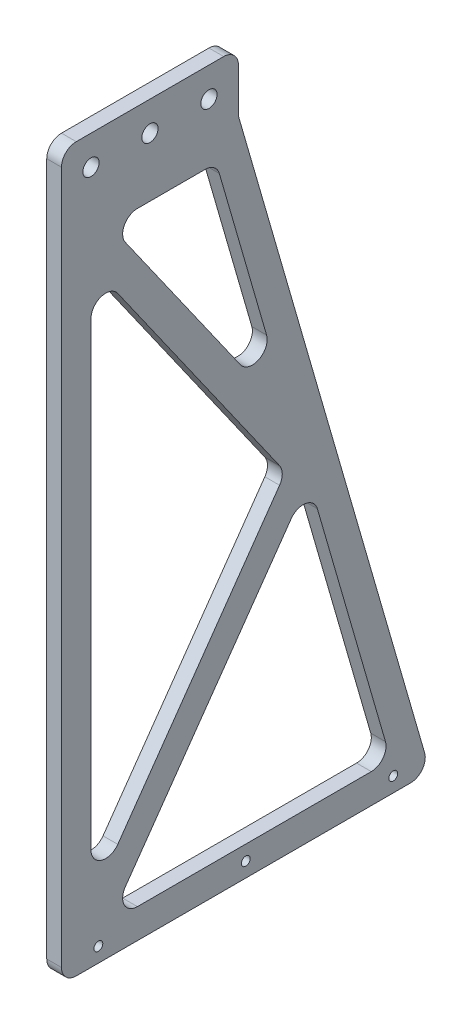
from build123d import *

# Parameters (mm, degrees)
SKETCH1_R            = 1.5
BOSS_EXTRUDE1_DEPTH  = 5
M5_CLEARANCE_HOLE1_D = 5.5
FILLET2_R            = 5


with BuildPart() as part:
    # Sketch1 → Boss-Extrude1 (new body)
    with BuildSketch(Plane(origin=(0, 0, 0), x_dir=(0, 0, -1), z_dir=(1, 0, 0))):
        Polygon((95, -235), (30, -10), (30, 10), (-30, 10), (-30, -235), align=None)
        with Locations((-17.5, -230)):
            Circle(SKETCH1_R, mode=Mode.SUBTRACT)
        with Locations((32.5, -230)):
            Circle(SKETCH1_R, mode=Mode.SUBTRACT)
        with Locations((82.5, -230)):
            Circle(SKETCH1_R, mode=Mode.SUBTRACT)
        Polygon((-13.887165787, -225), (53.870859832, -128.66078689), (81.702188063, -225), align=None, mode=Mode.SUBTRACT)
        Polygon((-20, -216.308695426), (-20, -28.691304574), (45.978242739, -122.5), align=None, mode=Mode.SUBTRACT)
        Polygon((22.479965841, -20), (47.830060977, -107.750329315), (-13.887165787, -20), align=None, mode=Mode.SUBTRACT)
    extrude(amount=BOSS_EXTRUDE1_DEPTH)

    # M5 Clearance Hole1 (through all)
    with Locations(Plane(origin=(5, 0, 0), x_dir=(0, 0, -1), z_dir=(1, 0, 0))):
        with Locations((0, 0), (20, 0), (-20, 0)):
            Hole(M5_CLEARANCE_HOLE1_D / 2)

    # Fillet2
    fillet2_edges = [part.edges().sort_by_distance(p)[0] for p in [
        (2.5, -235, -95),
        (2.5, -235, 30),
        (2.5, 10, 30),
        (2.5, 10, -30),
        (2.5, -10, -30),
        (2.5, -216.308695426, 20),
        (2.5, -122.5, -45.978242739),
        (2.5, -28.691304574, 20),
        (2.5, -20, -22.479965841),
        (2.5, -20, 13.887165787),
        (2.5, -107.750329315, -47.830060977),
        (2.5, -225, 13.887165787),
        (2.5, -225, -81.702188063),
        (2.5, -128.66078689, -53.870859832),
    ]]
    fillet(fillet2_edges, radius=FILLET2_R)


solid = part.part
